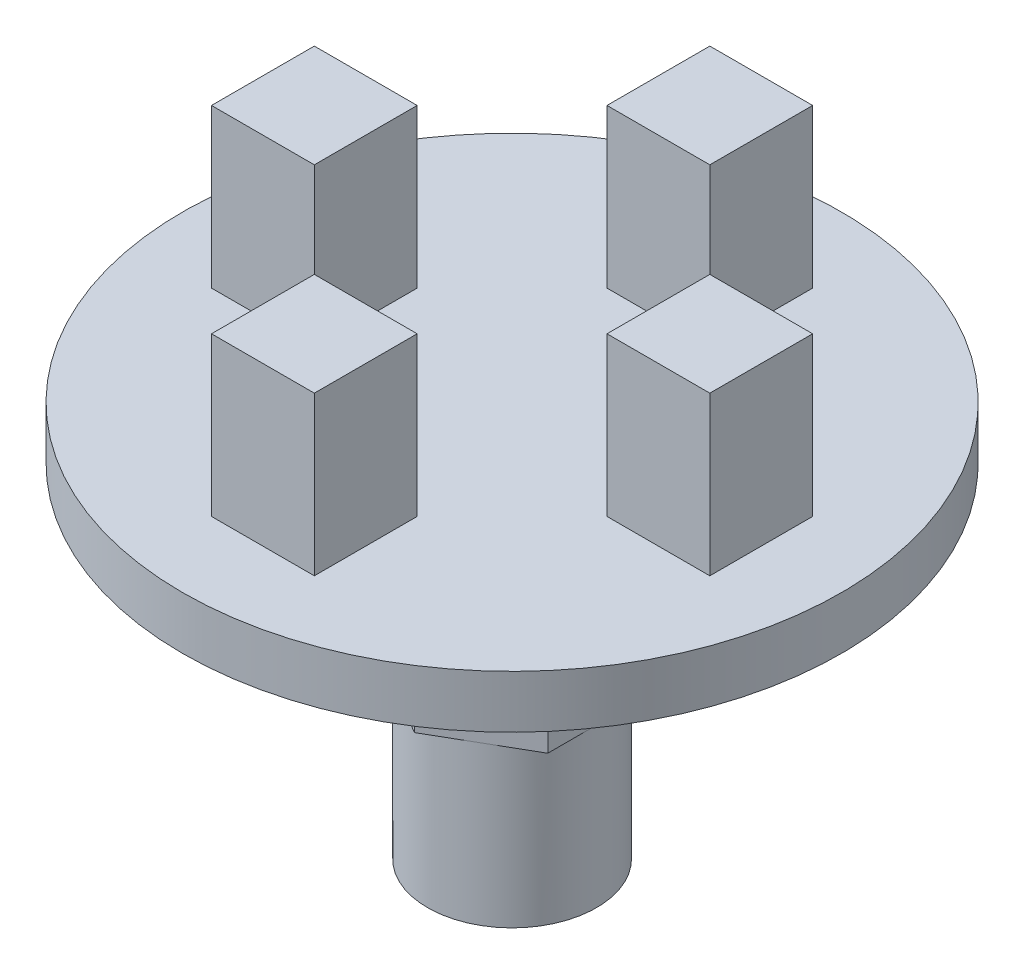
from build123d import *

# Parameters (mm, degrees)
SKETCH1_R           = 12.5
BOSS_EXTRUDE1_DEPTH = 1
SKETCH2_W           = 3.9
SKETCH2_H           = 3.9
BOSS_EXTRUDE3_DEPTH = 6
SKETCH3_R           = 5
BOSS_EXTRUDE4_DEPTH = 1
BOSS_EXTRUDE5_DEPTH = 6
SKETCH5_R           = 3.204293994
BOSS_EXTRUDE6_DEPTH = 6


with BuildPart() as part:
    # Sketch1 → Boss-Extrude1 (new body, symmetric)
    with BuildSketch(Plane(origin=(0, 0, 0), x_dir=(1, 0, 0), z_dir=(0, 1, 0))):
        Circle(SKETCH1_R)
    extrude(amount=BOSS_EXTRUDE1_DEPTH, both=True)

    # Sketch2 → Boss-Extrude3 (add)
    with BuildSketch(Plane(origin=(0, 1, 0), x_dir=(1, 0, 0), z_dir=(0, 1, 0))):
        with Locations((0, 7.5)):
            Rectangle(SKETCH2_W, SKETCH2_H)
        with Locations((7.5, 0)):
            Rectangle(SKETCH2_W, SKETCH2_H)
        with Locations((0, -7.5)):
            Rectangle(SKETCH2_W, SKETCH2_H)
        with Locations((-7.5, 0)):
            Rectangle(SKETCH2_W, SKETCH2_H)
    extrude(amount=BOSS_EXTRUDE3_DEPTH)

    # Sketch3 → Boss-Extrude4 (add)
    with BuildSketch(Plane.XZ.offset(1)):
        Circle(SKETCH3_R)
    extrude(amount=BOSS_EXTRUDE4_DEPTH)

    # Sketch4 → Boss-Extrude5 (add)
    with BuildSketch(Plane.XZ.offset(2)):
        Polygon((0, -3.7), (3.204293994, -1.85), (3.204293994, 1.85), (0, 3.7), (-3.204293994, 1.85), (-3.204293994, -1.85), align=None)
    extrude(amount=BOSS_EXTRUDE5_DEPTH)

    # Sketch5 → Boss-Extrude6 (add)
    with BuildSketch(Plane(origin=(0, -8, 0), x_dir=(-1, 0, 0), z_dir=(0, -1, 0))):
        Circle(SKETCH5_R)
    extrude(amount=BOSS_EXTRUDE6_DEPTH)


solid = part.part
